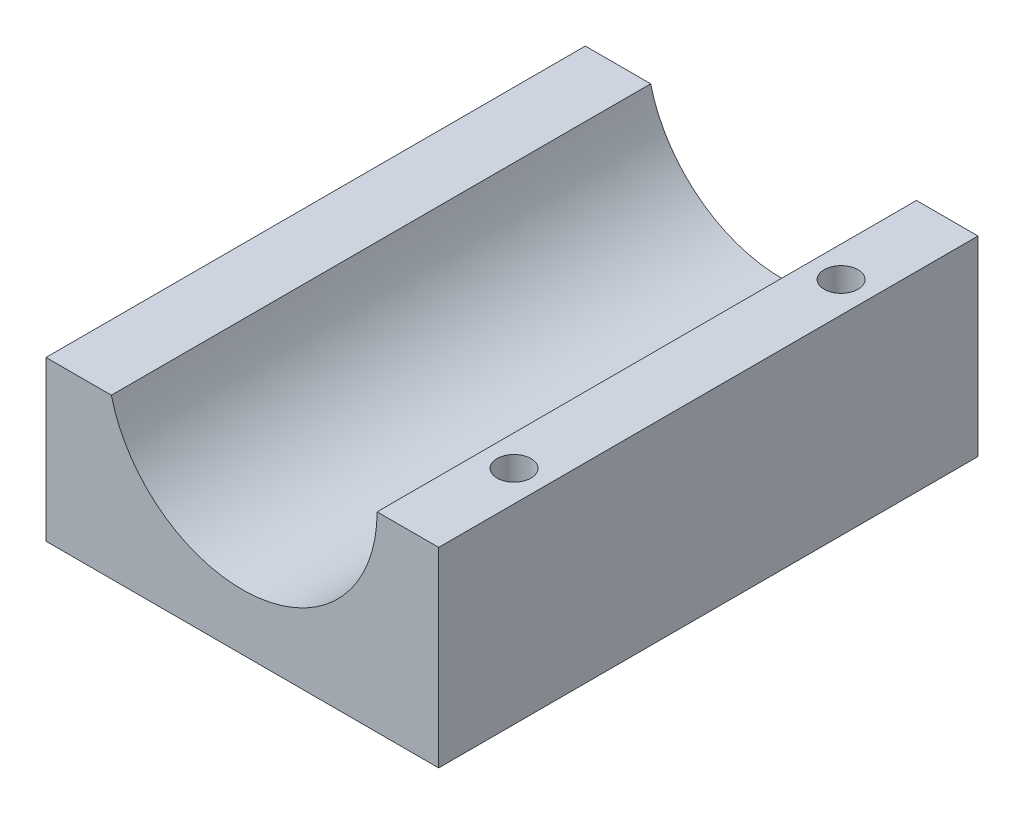
from build123d import *

# Parameters (mm, degrees)
SKETCH2_W               = 18.5
SKETCH2_H               = 25.41
BOSS_EXTRUDE1_DEPTH     = 9
CUT_EXTRUDE1_DEPTH      = 25.41
CUT_EXTRUDE3_DEPTH      = 33.694312961
CUT_EXTRUDE3_DEPTH_BACK = 25.41
SKETCH10_R              = 0.8
CUT_EXTRUDE4_DEPTH      = 33.694312961


with BuildPart() as part:
    # Sketch2 → Boss-Extrude1 (new body)
    with BuildSketch(Plane(origin=(0, 0, 0), x_dir=(1, 0, 0), z_dir=(0, 1, 0))):
        with Locations((9.25, 12.705)):
            Rectangle(SKETCH2_W, SKETCH2_H)
    extrude(amount=BOSS_EXTRUDE1_DEPTH)

    # Sketch6 → Cut-Extrude1 (cut)
    with BuildSketch(Plane.XY):
        with BuildLine():
            Line((2.9, 9), (15.6, 9))
            ThreePointArc((15.6, 9), (9.25, 2.65), (2.9, 9))
        make_face()
    extrude(amount=-CUT_EXTRUDE1_DEPTH, mode=Mode.SUBTRACT)

    # Sketch14 → Cut-Extrude3 (cut, two sides)
    with BuildSketch(Plane(origin=(0, 0, -25.41), x_dir=(-1, 0, 0), z_dir=(0, 0, -1))) as cut_extrude3_sk:
        Polygon((0, 60.146081223), (0, 9), (0, 7.5), (-3.246658661, 7.5), (-2.9, 9), (8.616604878, 58.832614185), (24.031387378, 159.956651774), (15.4147825, 161.270118812), align=None)
    extrude(amount=CUT_EXTRUDE3_DEPTH, mode=Mode.SUBTRACT)
    extrude(cut_extrude3_sk.sketch, amount=-CUT_EXTRUDE3_DEPTH_BACK, mode=Mode.SUBTRACT)


with BuildPart() as cut_extrude3_kept_piece:
    # of the separate pieces the step leaves, the one the design keeps (cut_extrude3_pieces_kept)
    add(part.part.solids().sort_by_distance((0, 0, 0))[0])

    # Sketch10 → Cut-Extrude4 (cut, through all)
    with BuildSketch(Plane(origin=(0, 9, 0), x_dir=(1, 0, 0), z_dir=(0, 1, 0))):
        with Locations(Location((17.05, 20.41, 0), (0, 0, 270))):
            Circle(SKETCH10_R)
        with Locations(Location((17.05, 5, 0), (0, 0, 270))):
            Circle(SKETCH10_R)
    extrude(amount=-CUT_EXTRUDE4_DEPTH, mode=Mode.SUBTRACT)


solid = cut_extrude3_kept_piece.part
